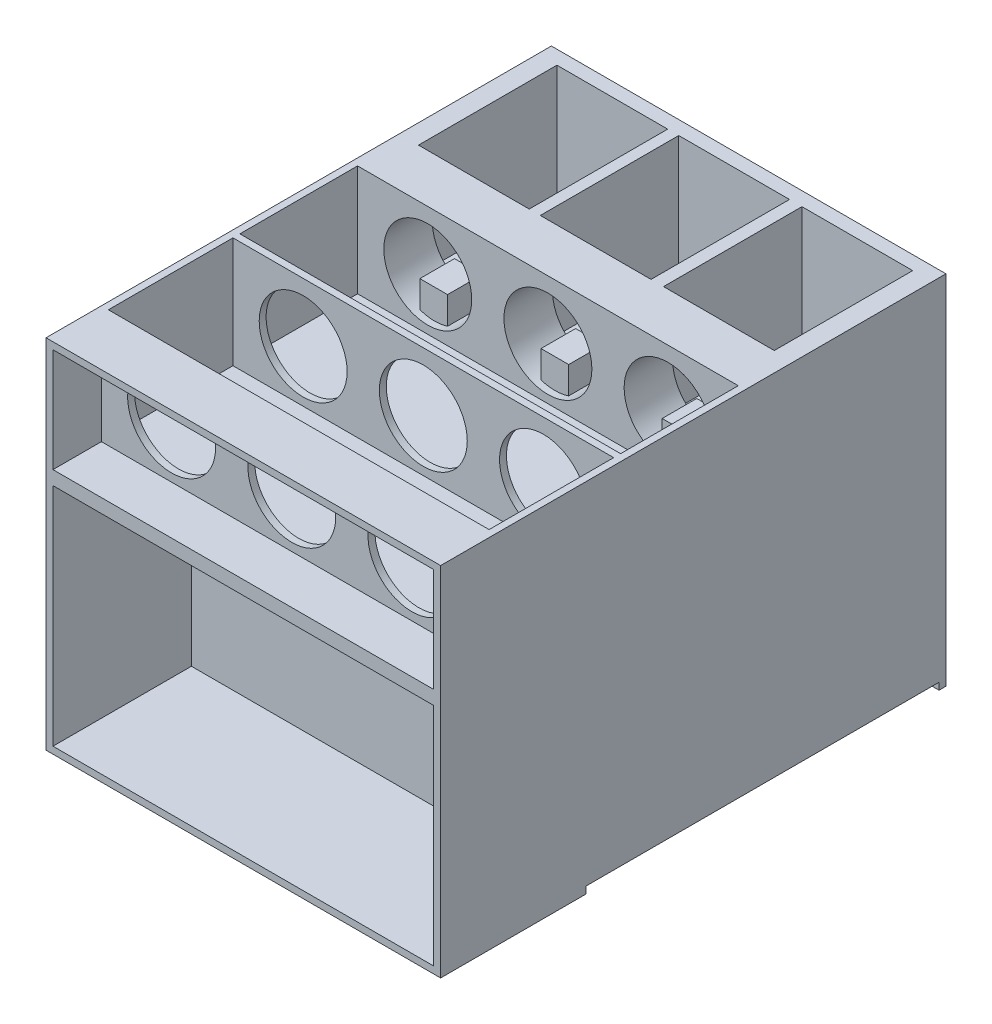
from build123d import *

# Parameters (mm, degrees)
SKETCH2_W           = 285
SKETCH2_H           = 258
BOSS_EXTRUDE1_DEPTH = 365
SKETCH3_W           = 275
SKETCH3_H           = 75
CUT_EXTRUDE1_DEPTH  = 35
SKETCH5_W           = 80
SKETCH5_H           = 100
CUT_EXTRUDE2_DEPTH  = 81
SKETCH4_R           = 31.75
CUT_EXTRUDE4_DEPTH  = 276
SKETCH6_W           = 275
SKETCH6_H           = 85
SKETCH6_H_2         = 90
CUT_EXTRUDE6_DEPTH  = 80
SKETCH8_W           = 275
SKETCH8_H           = 163
CUT_EXTRUDE10_DEPTH = 100
SKETCH16_W          = 285
SKETCH16_H          = 255
CUT_EXTRUDE11_DEPTH = 5
SKETCH17_W          = 255
SKETCH17_H          = 230
CUT_EXTRUDE12_DEPTH = 165
SKETCH18_W          = 255
SKETCH18_H          = 10
BOSS_EXTRUDE2_DEPTH = 35
SKETCH19_W          = 20
SKETCH19_H          = 25
BOSS_EXTRUDE3_DEPTH = 35
SKETCH20_W          = 20
SKETCH20_H          = 25
BOSS_EXTRUDE4_DEPTH = 35


with BuildPart() as part:
    # Sketch2 → Boss-Extrude1 (new body)
    with BuildSketch(Plane.XY):
        with Locations((9.388446215, -14.647410359)):
            Rectangle(SKETCH2_W, SKETCH2_H)
    extrude(amount=BOSS_EXTRUDE1_DEPTH)

    # Sketch3 → Cut-Extrude1 (cut)
    with BuildSketch(Plane.XY.offset(365)):
        with Locations((9.388446215, 71.852589641)):
            Rectangle(SKETCH3_W, SKETCH3_H)
    extrude(amount=-CUT_EXTRUDE1_DEPTH, mode=Mode.SUBTRACT)

    # Sketch5 → Cut-Extrude2 (cut)
    with BuildSketch(Plane(origin=(0, 114.352589641, 0), x_dir=(1, 0, 0), z_dir=(0, 1, 0))):
        with Locations((-79.111553785, -60)):
            Rectangle(SKETCH5_W, SKETCH5_H)
        with Locations((8.888446215, -60)):
            Rectangle(SKETCH5_W, SKETCH5_H)
        with Locations((97.888446215, -60)):
            Rectangle(SKETCH5_W, SKETCH5_H)
    extrude(amount=-CUT_EXTRUDE2_DEPTH, mode=Mode.SUBTRACT)

    # Sketch4 → Cut-Extrude4 (cut)
    with BuildSketch(Plane.XY.offset(330)):
        with Locations((-77.411553785, 71.852589641)):
            Circle(SKETCH4_R)
        with Locations((9.388446215, 71.852589641)):
            Circle(SKETCH4_R)
        with Locations((96.188446215, 71.852589641)):
            Circle(SKETCH4_R)
    extrude(amount=-CUT_EXTRUDE4_DEPTH, mode=Mode.SUBTRACT)

    # Sketch6 → Cut-Extrude6 (cut)
    with BuildSketch(Plane(origin=(0, 114.352589641, 0), x_dir=(1, 0, 0), z_dir=(0, 1, 0))):
        with Locations((9.388446215, -187.5)):
            Rectangle(SKETCH6_W, SKETCH6_H)
        with Locations((9.388446215, -280)):
            Rectangle(SKETCH6_W, SKETCH6_H_2)
    extrude(amount=-CUT_EXTRUDE6_DEPTH, mode=Mode.SUBTRACT)

    # Sketch8 → Cut-Extrude10 (cut)
    with BuildSketch(Plane.XY.offset(365)):
        with Locations((9.388446215, -57.147410359)):
            Rectangle(SKETCH8_W, SKETCH8_H)
    extrude(amount=-CUT_EXTRUDE10_DEPTH, mode=Mode.SUBTRACT)

    # Sketch16 → Cut-Extrude11 (cut)
    with BuildSketch(Plane.XZ.offset(143.647410359)):
        with Locations((9.388446215, 132.5)):
            Rectangle(SKETCH16_W, SKETCH16_H)
    extrude(amount=-CUT_EXTRUDE11_DEPTH, mode=Mode.SUBTRACT)

    # Sketch17 → Cut-Extrude12 (cut)
    with BuildSketch(Plane.XZ.offset(138.647410359)):
        with Locations((9.388446215, 130)):
            Rectangle(SKETCH17_W, SKETCH17_H)
    extrude(amount=-CUT_EXTRUDE12_DEPTH, mode=Mode.SUBTRACT)

    # Sketch18 → Boss-Extrude2 (add)
    with BuildSketch(Plane.XZ.offset(-26.352589641)):
        with Locations((9.388446215, 145)):
            Rectangle(SKETCH18_W, SKETCH18_H)
    extrude(amount=BOSS_EXTRUDE2_DEPTH)

    # Sketch19 → Boss-Extrude3 (add, symmetric)
    with BuildSketch(Plane.XZ.offset(-26.352589641)):
        with Locations((9.388446215, 127.5)):
            Rectangle(SKETCH19_W, SKETCH19_H)
    extrude(amount=BOSS_EXTRUDE3_DEPTH, both=True)

    # Sketch20 → Boss-Extrude4 (add, symmetric)
    with BuildSketch(Plane.XZ.offset(-26.352589641)):
        with Locations((-78.111553785, 127.5)):
            Rectangle(SKETCH20_W, SKETCH20_H)
        with Locations((96.888446215, 127.5)):
            Rectangle(SKETCH20_W, SKETCH20_H)
    extrude(amount=BOSS_EXTRUDE4_DEPTH, both=True)


solid = part.part
